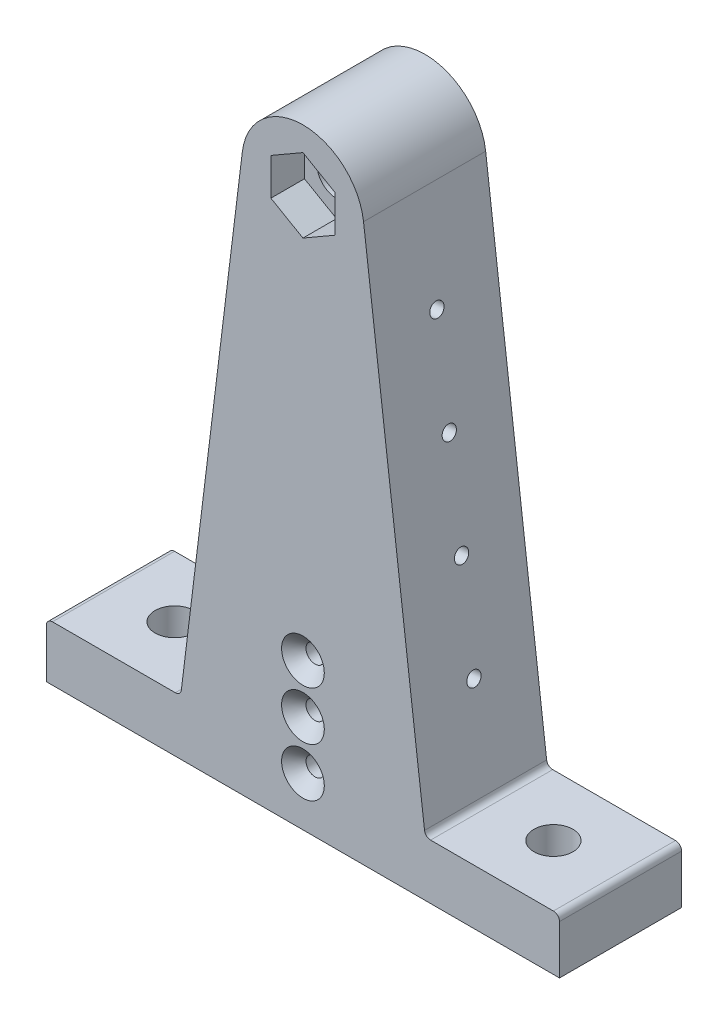
from build123d import *

# Parameters (mm, degrees)
SKETCH1_R           = 3.2
BOSS_EXTRUDE1_DEPTH = 20
SKETCH3_R           = 3.2
CUT_EXTRUDE1_DEPTH  = 10
CUT_EXTRUDE2_DEPTH  = 5.5
SKETCH6_R           = 1.5
CUT_EXTRUDE4_DEPTH  = 21
CHAMFER1_SIZE       = 2
SKETCH8_R           = 1.16
CUT_EXTRUDE5_DEPTH  = 10
FILLET1_R           = 1


with BuildPart() as part:
    # Sketch1 → Boss-Extrude1 (new body)
    with BuildSketch(Plane.XY):
        with BuildLine():
            Line((20.020647688, -81), (9.925461516, 1.218693434))
            ThreePointArc((9.925461516, 1.218693434), (0, 10), (-9.925461516, 1.218693434))
            Line((-9.925461516, 1.218693434), (-20.020647688, -81))
            Line((-20.020647688, -81), (-42.020647688, -81))
            Line((-42.020647688, -81), (-42.020647688, -90))
            Line((-42.020647688, -90), (42.020647688, -90))
            Line((42.020647688, -90), (42.020647688, -81))
            Line((42.020647688, -81), (20.020647688, -81))
        make_face()
        Circle(SKETCH1_R, mode=Mode.SUBTRACT)
    extrude(amount=BOSS_EXTRUDE1_DEPTH)

    # Sketch3 → Cut-Extrude1 (cut, through all)
    with BuildSketch(Plane(origin=(0, -81, 0), x_dir=(1, 0, 0), z_dir=(0, 1, 0))):
        with Locations((-31.020647688, -10)):
            Circle(SKETCH3_R)
        with Locations((31.020647688, -10)):
            Circle(SKETCH3_R)
    extrude(amount=-CUT_EXTRUDE1_DEPTH, mode=Mode.SUBTRACT)

    # Sketch4 → Cut-Extrude2 (cut)
    with BuildSketch(Plane.XY.offset(20)):
        Polygon((0, 6.062177826), (-5.25, 3.031088913), (-5.25, -3.031088913), (0, -6.062177826), (5.25, -3.031088913), (5.25, 3.031088913), align=None)
    extrude(amount=-CUT_EXTRUDE2_DEPTH, mode=Mode.SUBTRACT)

    # Sketch6 → Cut-Extrude4 (cut, through all)
    with BuildSketch(Plane.XY.offset(20)):
        with Locations((0, -66)):
            Circle(SKETCH6_R)
        with Locations((0, -74)):
            Circle(SKETCH6_R)
        with Locations((0, -82)):
            Circle(SKETCH6_R)
    extrude(amount=-CUT_EXTRUDE4_DEPTH, mode=Mode.SUBTRACT)

    # Chamfer1
    chamfer1_edges = [part.edges().sort_by_distance(p)[0] for p in [
        (-1.5, -66, 20),
        (-1.5, -74, 20),
        (-1.5, -82, 20),
    ]]
    chamfer(chamfer1_edges, length=CHAMFER1_SIZE)

    # Sketch8 → Cut-Extrude5 (cut)
    with BuildSketch(Plane(origin=(-9.925461516, 1.218693434, 0), x_dir=(0, 0, 1), z_dir=(-0.992546152, 0.121869343, 0))):
        with Locations((10, -16.567228294)):
            Circle(SKETCH8_R)
        with Locations((10, -33.134456588)):
            Circle(SKETCH8_R)
        with Locations((10, -49.701684883)):
            Circle(SKETCH8_R)
        with Locations((10, -66.268913177)):
            Circle(SKETCH8_R)
    cut_extrude5 = extrude(amount=-CUT_EXTRUDE5_DEPTH, mode=Mode.SUBTRACT)

    # Mirror1: Cut-Extrude5 across plane
    add(cut_extrude5.mirror(Plane(origin=(0, 0, 0), x_dir=(0, 0, 1), z_dir=(1, 0, 0))), mode=Mode.SUBTRACT)

    # Fillet1
    fillet1_edges = [part.edges().sort_by_distance(p)[0] for p in [
        (-42.020647688, -81, 10),
        (-20.020647688, -81, 10),
        (20.020647688, -81, 10),
        (42.020647688, -81, 10),
    ]]
    fillet(fillet1_edges, radius=FILLET1_R)


solid = part.part
